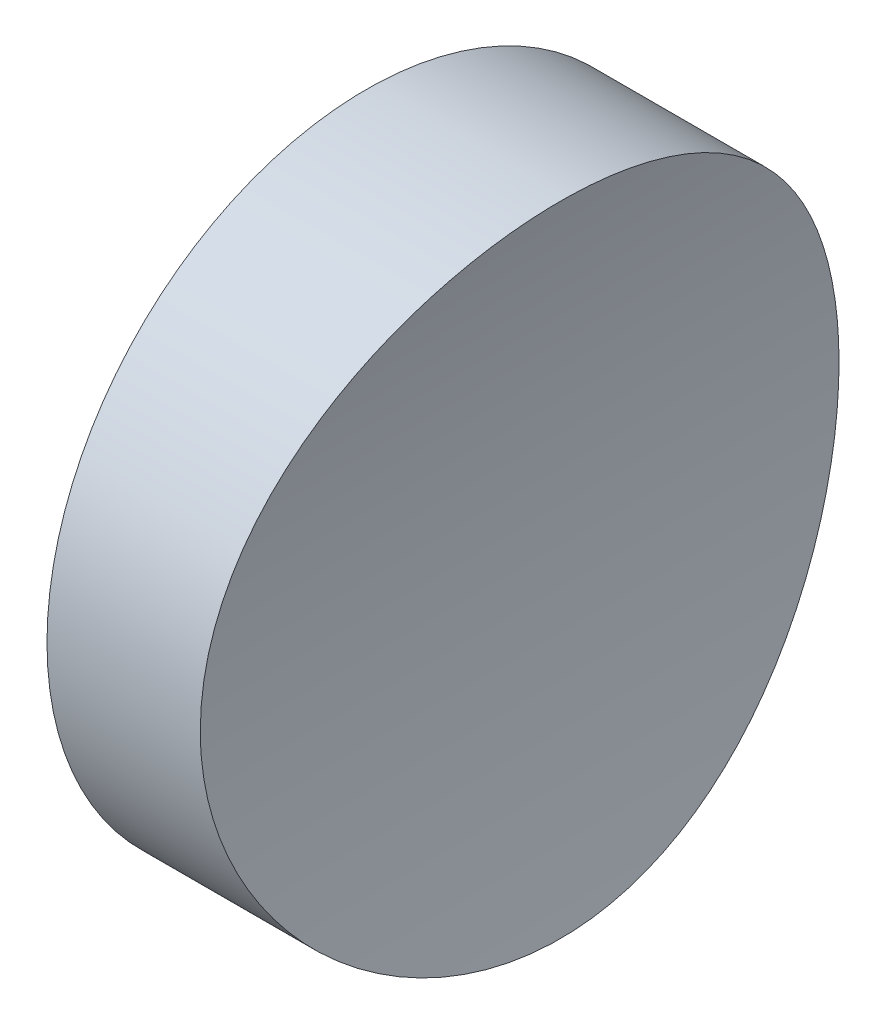
from build123d import *

# Parameters (mm, degrees)
SKETCH_1_R               = 12.5
EXTRUDE_1_DEPTH          = 10
SKETCH_2_R               = 50
CUT_EXTRUDE_1_DEPTH      = 13.5
CUT_EXTRUDE_1_DEPTH_BACK = 13.5


with BuildPart() as part:
    # 草图1 → 凸台-拉伸1 (new body)
    with BuildSketch(Plane(origin=(0, 0, 0), x_dir=(0, 0, -1), z_dir=(1, 0, 0))):
        Circle(SKETCH_1_R)
    extrude(amount=EXTRUDE_1_DEPTH)

    # 草图2 → 切除-拉伸1 (cut, two sides)
    with BuildSketch(Plane.XY) as cut_extrude_1_sk:
        with Locations((56, 0)):
            Circle(SKETCH_2_R)
    extrude(amount=CUT_EXTRUDE_1_DEPTH, mode=Mode.SUBTRACT)
    extrude(cut_extrude_1_sk.sketch, amount=-CUT_EXTRUDE_1_DEPTH_BACK, mode=Mode.SUBTRACT)


solid = part.part
